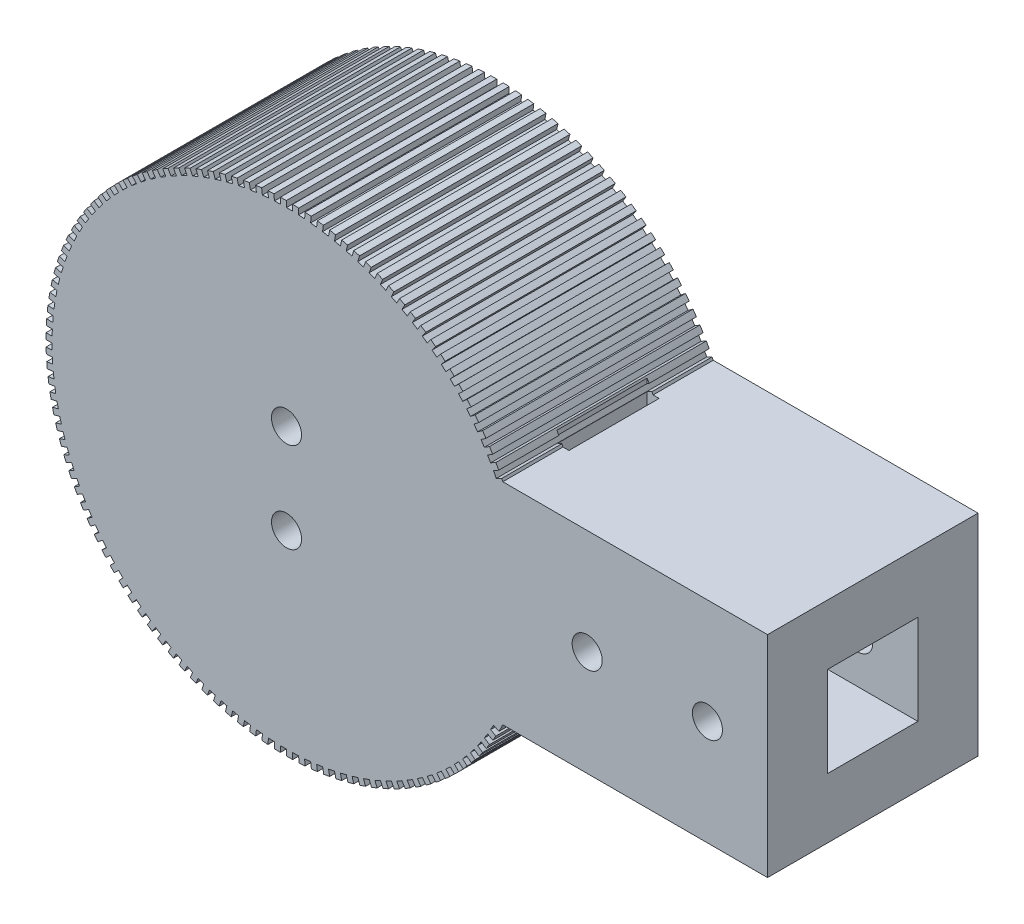
from build123d import *

# Parameters (mm, degrees)
SKETCH1_R               = 40
BOSS_EXTRUDE1_DEPTH     = 35
SKETCH2_W               = 35
SKETCH2_H               = 35
BOSS_EXTRUDE2_DEPTH     = 80
SKETCH3_R               = 2.5
CUT_EXTRUDE1_DEPTH      = 1
CUT_EXTRUDE1_DEPTH_BACK = 36
SKETCH4_W               = 2
SKETCH4_H               = 15
CUT_EXTRUDE2_DEPTH      = 23.5
CUT_EXTRUDE2_DEPTH_BACK = 58.5
SKETCH6_W               = 15
SKETCH6_H               = 15
CUT_EXTRUDE4_DEPTH      = 47.5
SKETCH7_R               = 2.5
CUT_EXTRUDE5_DEPTH      = 1
CUT_EXTRUDE5_DEPTH_BACK = 36
CUT_EXTRUDE9_DEPTH      = 36


with BuildPart() as part:
    # Sketch1 → Boss-Extrude1 (new body)
    with BuildSketch(Plane.XY):
        Circle(SKETCH1_R)
    extrude(amount=BOSS_EXTRUDE1_DEPTH)

    # Sketch2 → Boss-Extrude2 (add)
    with BuildSketch(Plane(origin=(0, 0, 0), x_dir=(0, 0, -1), z_dir=(1, 0, 0))):
        with Locations((-17.5, 0)):
            Rectangle(SKETCH2_W, SKETCH2_H)
    extrude(amount=BOSS_EXTRUDE2_DEPTH)

    # Sketch3 → Cut-Extrude1 (cut, two sides)
    with BuildSketch(Plane(origin=(0, 0, 0), x_dir=(-1, 0, 0), z_dir=(0, 0, -1))) as cut_extrude1_sk:
        with Locations((0, 7.5)):
            Circle(SKETCH3_R)
        with Locations((0, -7.5)):
            Circle(SKETCH3_R)
    extrude(amount=CUT_EXTRUDE1_DEPTH, mode=Mode.SUBTRACT)
    extrude(cut_extrude1_sk.sketch, amount=-CUT_EXTRUDE1_DEPTH_BACK, mode=Mode.SUBTRACT)

    # Sketch4 → Cut-Extrude2 (cut, two sides)
    with BuildSketch(Plane(origin=(0, 17.5, 0), x_dir=(1, 0, 0), z_dir=(0, 1, 0))) as cut_extrude2_sk:
        with Locations((35.968736425, -17.5)):
            Rectangle(SKETCH4_W, SKETCH4_H)
    extrude(amount=CUT_EXTRUDE2_DEPTH, mode=Mode.SUBTRACT)
    extrude(cut_extrude2_sk.sketch, amount=-CUT_EXTRUDE2_DEPTH_BACK, mode=Mode.SUBTRACT)

    # Sketch6 → Cut-Extrude4 (cut)
    with BuildSketch(Plane(origin=(80, 0, 0), x_dir=(0, 0, -1), z_dir=(1, 0, 0))):
        with Locations((-17.5, 0)):
            Rectangle(SKETCH6_W, SKETCH6_H)
    extrude(amount=-CUT_EXTRUDE4_DEPTH, mode=Mode.SUBTRACT)

    # Sketch7 → Cut-Extrude5 (cut, two sides)
    with BuildSketch(Plane.XY.offset(35)) as cut_extrude5_sk:
        with Locations((50, 0)):
            Circle(SKETCH7_R)
        with Locations((70, 0)):
            Circle(SKETCH7_R)
    extrude(amount=CUT_EXTRUDE5_DEPTH, mode=Mode.SUBTRACT)
    extrude(cut_extrude5_sk.sketch, amount=-CUT_EXTRUDE5_DEPTH_BACK, mode=Mode.SUBTRACT)

    # Sketch8 → Cut-Extrude9 (cut, through all)
    with BuildSketch(Plane.XY.offset(35)):
        with BuildLine():
            Line((-39, 0), (-40.006638535, 0))
            Line((-40.006638535, 0), (-39.994138656, 1))
            Line((-39.994138656, 1), (-38.987177379, 1))
            Line((-38.987177379, 1), (-38.948289506, 2.007671436))
            Line((-38.948289506, 2.007671436), (-39.953593328, 2.059491934))
            Line((-39.953593328, 2.059491934), (-39.889631269, 3.057522546))
            Line((-39.889631269, 3.057522546), (-38.884005132, 3.005685433))
            Line((-38.884005132, 3.005685433), (-38.793295149, 4.010018888))
            Line((-38.793295149, 4.010018888), (-39.794598375, 4.113522466))
            Line((-39.794598375, 4.113522466), (-39.67934375, 5.106937092))
            Line((-39.67934375, 5.106937092), (-38.677719493, 5.003400329))
            Line((-38.677719493, 5.003400329), (-38.535427948, 6.001732491))
            Line((-38.535427948, 6.001732491), (-39.5300753, 6.156644676))
            Line((-39.5300753, 6.156644676), (-39.363833744, 7.142808959))
            Line((-39.363833744, 7.142808959), (-38.368867494, 6.987847107))
            Line((-38.368867494, 6.987847107), (-38.175371719, 7.977530579))
            Line((-38.175371719, 7.977530579), (-39.160725572, 8.183440571))
            Line((-39.160725572, 8.183440571), (-38.943937928, 9.15973938))
            Line((-38.943937928, 9.15973938), (-37.958268157, 8.95376337))
            Line((-37.958268157, 8.95376337), (-37.714081267, 9.932173689))
            Line((-37.714081267, 9.932173689), (-38.687528639, 10.188535453))
            Line((-38.687528639, 10.188535453), (-38.42076979, 11.15237982))
            Line((-38.42076979, 11.15237982), (-37.447010317, 10.895935863))
            Line((-37.447010317, 10.895935863), (-37.152779851, 11.860478461))
            Line((-37.152779851, 11.860478461), (-38.111739335, 12.16661217))
            Line((-38.111739335, 12.16661217), (-37.795716677, 13.115446152))
            Line((-37.795716677, 13.115446152), (-36.836449737, 12.809214292))
            Line((-36.836449737, 12.809214292), (-36.492955943, 13.757331375))
            Line((-36.492955943, 13.757331375), (-37.434884551, 14.112425219))
            Line((-37.434884551, 14.112425219), (-37.070436117, 15.04373268))
            Line((-37.070436117, 15.04373268), (-36.128205514, 14.688524988))
            Line((-36.128205514, 14.688524988), (-35.736359275, 15.61770232))
            Line((-35.736359275, 15.61770232), (-36.658759181, 16.020814653))
            Line((-36.658759181, 16.020814653), (-36.246851426, 16.932125933))
            Line((-36.246851426, 16.932125933), (-35.324155785, 16.528884356))
            Line((-35.324155785, 16.528884356), (-34.884996207, 17.436657926))
            Line((-34.884996207, 17.436657926), (-35.785421373, 17.886719767))
            Line((-35.785421373, 17.886719767), (-35.3271466, 18.775618231))
            Line((-35.3271466, 18.775618231), (-34.426432745, 18.325412094))
            Line((-34.426432745, 18.325412094), (-33.9411244, 19.20937465))
            Line((-33.9411244, 19.20937465), (-34.81718706, 19.705192516))
            Line((-34.81718706, 19.705192516), (-34.313760532, 20.569320966))
            Line((-34.313760532, 20.569320966), (-33.437416995, 20.073344134))
            Line((-33.437416995, 20.073344134), (-32.907246833, 20.931151566))
            Line((-32.907246833, 20.931151566), (-33.756623827, 21.471410636))
            Line((-33.756623827, 21.471410636), (-33.209380541, 22.308477559))
            Line((-33.209380541, 22.308477559), (-32.359731225, 21.768045274))
            Line((-32.359731225, 21.768045274), (-31.786105163, 22.59742283))
            Line((-31.786105163, 22.59742283), (-32.606544095, 23.180690435))
            Line((-32.606544095, 23.180690435), (-32.016935241, 23.98847608))
            Line((-32.016935241, 23.98847608), (-31.196233266, 23.40502147))
            Line((-31.196233266, 23.40502147), (-30.580672456, 24.203769791))
            Line((-30.580672456, 24.203769791), (-31.36999767, 24.828499211))
            Line((-31.36999767, 24.828499211), (-30.739586786, 25.604861474))
            Line((-30.739586786, 25.604861474), (-29.950008504, 24.979931758))
            Line((-29.950008504, 24.979931758), (-29.294145304, 25.745932706))
            Line((-29.294145304, 25.745932706), (-30.05026365, 26.41046727))
            Line((-30.05026365, 26.41046727), (-29.380722472, 27.153347379))
            Line((-29.380722472, 27.153347379), (-28.624361703, 26.488599757))
            Line((-28.624361703, 26.488599757), (-27.929935344, 27.219822036))
            Line((-27.929935344, 27.219822036), (-28.650841734, 27.922399517))
            Line((-28.650841734, 27.922399517), (-27.943945764, 28.629827489))
            Line((-27.943945764, 28.629827489), (-27.222808242, 27.927024751))
            Line((-27.222808242, 27.927024751), (-26.491660217, 28.621529291))
            Line((-26.491660217, 28.621529291), (-27.175442936, 29.360286581))
            Line((-27.175442936, 29.360286581), (-26.433066735, 30.030386442))
            Line((-26.433066735, 30.030386442), (-25.749064786, 29.291392296))
            Line((-25.749064786, 29.291392296), (-24.983133969, 29.947337395))
            Line((-24.983133969, 29.947337395), (-25.627979748, 30.720315443))
            Line((-25.627979748, 30.720315443), (-24.852091965, 31.351310209))
            Line((-24.852091965, 31.351310209), (-24.20703944, 30.578084334))
            Line((-24.20703944, 30.578084334), (-23.408356941, 31.193730545))
            Line((-23.408356941, 31.193730545), (-24.012555765, 31.99887955))
            Line((-24.012555765, 31.99887955), (-23.205213915, 32.589095938))
            Line((-23.205213915, 32.589095938), (-22.600821377, 31.78368879))
            Line((-22.600821377, 31.78368879), (-21.771505159, 32.357403529))
            Line((-21.771505159, 32.357403529), (-22.333454802, 33.192588382))
            Line((-22.333454802, 33.192588382), (-21.496799809, 33.740461242))
            Line((-21.496799809, 33.740461242), (-20.934669998, 32.905008617))
            Line((-20.934669998, 32.905008617), (-20.076919259, 33.435270495))
            Line((-20.076919259, 33.435270495), (-20.59512953, 34.298276436))
            Line((-20.59512953, 34.298276436), (-19.731380055, 34.802352909))
            Line((-19.731380055, 34.802352909), (-19.213003638, 33.939070276))
            Line((-19.213003638, 33.939070276), (-18.329092978, 34.424473135))
            Line((-18.329092978, 34.424473135), (-18.802189678, 35.313011627))
            Line((-18.802189678, 35.313011627), (-17.913636228, 35.771954992))
            Line((-17.913636228, 35.771954992), (-17.440387846, 34.883131622))
            Line((-17.440387846, 34.883131622), (-16.532661238, 35.32238826))
            Line((-16.532661238, 35.32238826), (-16.959389799, 36.234103059))
            Line((-16.959389799, 36.234103059), (-16.048388657, 36.646696282))
            Line((-16.048388657, 36.646696282), (-15.621523281, 35.734689174))
            Line((-15.621523281, 35.734689174), (-14.692387852, 36.126634762))
            Line((-14.692387852, 36.126634762), (-15.071616667, 37.059108164))
            Line((-15.071616667, 37.059108164), (-14.140583646, 37.424257121))
            Line((-14.140583646, 37.424257121), (-13.761233245, 36.491484754))
            Line((-13.761233245, 36.491484754), (-12.813152895, 36.835079923))
            Line((-12.813152895, 36.835079923), (-13.143876317, 37.785839176))
            Line((-13.143876317, 37.785839176), (-12.195280348, 38.102575557))
            Line((-12.195280348, 38.102575557), (-11.864450891, 37.151511477))
            Line((-11.864450891, 37.151511477), (-10.899939759, 37.445845073))
            Line((-10.899939759, 37.445845073), (-11.181280769, 38.412368935))
            Line((-11.181280769, 38.412368935), (-10.217637359, 38.679852813))
            Line((-10.217637359, 38.679852813), (-9.936206147, 37.71301907))
            Line((-9.936206147, 37.71301907), (-8.957821943, 37.957310574))
            Line((-8.957821943, 37.957310574), (-9.189034475, 38.937035998))
            Line((-9.189034475, 38.937035998), (-8.212899033, 39.154558053))
            Line((-8.212899033, 39.154558053), (-7.981612371, 38.174518516))
            Line((-7.981612371, 38.174518516), (-6.991949594, 38.368120111))
            Line((-6.991949594, 38.368120111), (-7.172420514, 39.35844904))
            Line((-7.172420514, 39.35844904), (-6.186381575, 39.525432444))
            Line((-6.186381575, 39.525432444), (-6.005852793, 38.534786002))
            Line((-6.005852793, 38.534786002), (-5.007535851, 38.677184291))
            Line((-5.007535851, 38.677184291), (-5.136786583, 39.675490551))
            Line((-5.136786583, 39.675490551), (-4.143458945, 39.791492493))
            Line((-4.143458945, 39.791492493), (-4.014166773, 38.792866163))
            Line((-4.014166773, 38.792866163), (-3.009843023, 38.883683531))
            Line((-3.009843023, 38.883683531), (-3.087530817, 39.887319794))
            Line((-3.087530817, 39.887319794), (-2.089548607, 39.952032658))
            Line((-2.089548607, 39.952032658), (-2.011835905, 38.948074616))
            Line((-2.011835905, 38.948074616), (-1.004168633, 38.987070233))
            Line((-1.004168633, 38.987070233), (-1.030087475, 39.993375035))
            Line((-1.030087475, 39.993375035), (-0.030097161, 40.006627214))
            Line((-0.030097161, 40.006627214), (-0.004170009, 38.999999777))
            Line((-0.004170009, 38.999999777), (1.004168633, 38.987070233))
            Line((1.004168633, 38.987070233), (1.030087475, 39.993375035))
            Line((1.030087475, 39.993375035), (2.029434096, 39.955131387))
            Line((2.029434096, 39.955131387), (2.003506944, 38.94850395))
            Line((2.003506944, 38.94850395), (3.009843023, 38.883683531))
            Line((3.009843023, 38.883683531), (3.087530817, 39.887319794))
            Line((3.087530817, 39.887319794), (4.08358366, 39.797681734))
            Line((4.08358366, 39.797681734), (4.005870958, 38.793723692))
            Line((4.005870958, 38.793723692), (5.007535851, 38.677184291))
            Line((5.007535851, 38.677184291), (5.136786583, 39.675490551))
            Line((5.136786583, 39.675490551), (6.126904293, 39.534695783))
            Line((6.126904293, 39.534695783), (5.997612121, 38.536069452))
            Line((5.997612121, 38.536069452), (6.991949594, 38.368120111))
            Line((6.991949594, 38.368120111), (7.172420514, 39.35844904))
            Line((7.172420514, 39.35844904), (8.153977478, 39.166870926))
            Line((8.153977478, 39.166870926), (7.973448696, 38.176224485))
            Line((7.973448696, 38.176224485), (8.957821943, 37.957310574))
            Line((8.957821943, 37.957310574), (9.189034475, 38.937035998))
            Line((9.189034475, 38.937035998), (10.15942778, 38.695182569))
            Line((10.15942778, 38.695182569), (9.928141118, 37.715143032))
            Line((9.928141118, 37.715143032), (10.899939759, 37.445845073))
            Line((10.899939759, 37.445845073), (11.181280769, 38.412368935))
            Line((11.181280769, 38.412368935), (12.137937106, 38.120881544))
            Line((12.137937106, 38.120881544), (11.856505895, 37.154047801))
            Line((11.856505895, 37.154047801), (12.813152895, 36.835079923))
            Line((12.813152895, 36.835079923), (13.143876317, 37.785839176))
            Line((13.143876317, 37.785839176), (14.084258805, 37.445490794))
            Line((14.084258805, 37.445490794), (13.753429349, 36.494426713))
            Line((13.753429349, 36.494426713), (14.692387852, 36.126634762))
            Line((14.692387852, 36.126634762), (15.071616667, 37.059108164))
            Line((15.071616667, 37.059108164), (15.993231582, 36.670801333))
            Line((15.993231582, 36.670801333), (15.613881181, 35.738028967))
            Line((15.613881181, 35.738028967), (16.532661238, 35.32238826))
            Line((16.532661238, 35.32238826), (16.959389799, 36.234103059))
            Line((16.959389799, 36.234103059), (17.859793184, 35.7988675))
            Line((17.859793184, 35.7988675), (17.432927807, 34.886860393))
            Line((17.432927807, 34.886860393), (18.329092978, 34.424473135))
            Line((18.329092978, 34.424473135), (18.802189678, 35.313011627))
            Line((18.802189678, 35.313011627), (19.678993824, 34.832001506))
            Line((19.678993824, 34.832001506), (19.205745443, 33.943178136))
            Line((19.205745443, 33.943178136), (20.076919259, 33.435270495))
            Line((20.076919259, 33.435270495), (20.59512953, 34.298276436))
            Line((20.59512953, 34.298276436), (21.446009311, 33.772767306))
            Line((21.446009311, 33.772767306), (20.927632894, 32.909484673))
            Line((20.927632894, 32.909484673), (21.771505159, 32.357403529))
            Line((21.771505159, 32.357403529), (22.333454802, 33.192588382))
            Line((22.333454802, 33.192588382), (23.156153836, 32.623973798))
            Line((23.156153836, 32.623973798), (22.594024025, 31.788521173))
            Line((22.594024025, 31.788521173), (23.408356941, 31.193730545))
            Line((23.408356941, 31.193730545), (24.012555765, 31.99887955))
            Line((24.012555765, 31.99887955), (24.804892405, 31.388667376))
            Line((24.804892405, 31.388667376), (24.200499866, 30.583260229))
            Line((24.200499866, 30.583260229), (24.983133969, 29.947337395))
            Line((24.983133969, 29.947337395), (25.627979748, 30.720315443))
            Line((25.627979748, 30.720315443), (26.387852857, 30.070123852))
            Line((26.387852857, 30.070123852), (25.742800332, 29.296897977))
            Line((25.742800332, 29.296897977), (26.491660217, 28.621529291))
            Line((26.491660217, 28.621529291), (27.175442936, 29.360286581))
            Line((27.175442936, 29.360286581), (27.900837468, 28.671839764))
            Line((27.900837468, 28.671839764), (27.216835519, 27.932845618))
            Line((27.216835519, 27.932845618), (27.929935344, 27.219822036))
            Line((27.929935344, 27.219822036), (28.650841734, 27.922399517))
            Line((28.650841734, 27.922399517), (29.339834073, 27.197523112))
            Line((29.339834073, 27.197523112), (28.618696551, 26.494720374))
            Line((28.618696551, 26.494720374), (29.294145304, 25.745932706))
            Line((29.294145304, 25.745932706), (30.05026365, 26.41046727))
            Line((30.05026365, 26.41046727), (30.701026713, 25.651083518))
            Line((30.701026713, 25.651083518), (29.944665945, 24.986335895))
            Line((29.944665945, 24.986335895), (30.580672456, 24.203769791))
            Line((30.580672456, 24.203769791), (31.36999767, 24.828499211))
            Line((31.36999767, 24.828499211), (31.980805749, 24.036621861))
            Line((31.980805749, 24.036621861), (31.191227467, 23.411692145))
            Line((31.191227467, 23.411692145), (31.786105163, 22.59742283))
            Line((31.786105163, 22.59742283), (32.606544095, 23.180690435))
            Line((32.606544095, 23.180690435), (33.175777438, 22.358419405))
            Line((33.175777438, 22.358419405), (32.355075462, 21.774964795))
            Line((32.355075462, 21.774964795), (32.907246833, 20.931151566))
            Line((32.907246833, 20.931151566), (33.756623827, 21.471410636))
            Line((33.756623827, 21.471410636), (34.282772929, 20.620926439))
            Line((34.282772929, 20.620926439), (33.433123613, 20.080494154))
            Line((33.433123613, 20.080494154), (33.9411244, 19.20937465))
            Line((33.9411244, 19.20937465), (34.81718706, 19.705192516))
            Line((34.81718706, 19.705192516), (35.298856668, 18.828750484))
            Line((35.298856668, 18.828750484), (34.422513131, 18.332773652))
            Line((34.422513131, 18.332773652), (34.884996207, 17.436657926))
            Line((34.884996207, 17.436657926), (35.785421373, 17.886719767))
            Line((35.785421373, 17.886719767), (45.709703325, 22.847199297))
            ThreePointArc((45.709703325, 22.847199297), (-51.10158015, 0), (45.709703325, -22.847199297))
            Line((45.709703325, -22.847199297), (35.785421373, -17.886719767))
            Line((35.785421373, -17.886719767), (35.3271466, -18.775618231))
            Line((35.3271466, -18.775618231), (34.426432745, -18.325412094))
            Line((34.426432745, -18.325412094), (33.9411244, -19.20937465))
            Line((33.9411244, -19.20937465), (34.81718706, -19.705192516))
            Line((34.81718706, -19.705192516), (34.313760532, -20.569320966))
            Line((34.313760532, -20.569320966), (33.437416995, -20.073344134))
            Line((33.437416995, -20.073344134), (32.907246833, -20.931151566))
            Line((32.907246833, -20.931151566), (33.756623827, -21.471410636))
            Line((33.756623827, -21.471410636), (33.209380541, -22.308477559))
            Line((33.209380541, -22.308477559), (32.359731225, -21.768045274))
            Line((32.359731225, -21.768045274), (31.786105163, -22.59742283))
            Line((31.786105163, -22.59742283), (32.606544095, -23.180690435))
            Line((32.606544095, -23.180690435), (32.016935241, -23.98847608))
            Line((32.016935241, -23.98847608), (31.196233266, -23.40502147))
            Line((31.196233266, -23.40502147), (30.580672456, -24.203769791))
            Line((30.580672456, -24.203769791), (31.36999767, -24.828499211))
            Line((31.36999767, -24.828499211), (30.739586786, -25.604861474))
            Line((30.739586786, -25.604861474), (29.950008504, -24.979931758))
            Line((29.950008504, -24.979931758), (29.294145304, -25.745932706))
            Line((29.294145304, -25.745932706), (30.05026365, -26.41046727))
            Line((30.05026365, -26.41046727), (29.380722472, -27.153347379))
            Line((29.380722472, -27.153347379), (28.624361703, -26.488599757))
            Line((28.624361703, -26.488599757), (27.929935344, -27.219822036))
            Line((27.929935344, -27.219822036), (28.650841734, -27.922399517))
            Line((28.650841734, -27.922399517), (27.943945764, -28.629827489))
            Line((27.943945764, -28.629827489), (27.222808242, -27.927024751))
            Line((27.222808242, -27.927024751), (26.491660217, -28.621529291))
            Line((26.491660217, -28.621529291), (27.175442936, -29.360286581))
            Line((27.175442936, -29.360286581), (26.433066735, -30.030386442))
            Line((26.433066735, -30.030386442), (25.749064786, -29.291392296))
            Line((25.749064786, -29.291392296), (24.983133969, -29.947337395))
            Line((24.983133969, -29.947337395), (25.627979748, -30.720315443))
            Line((25.627979748, -30.720315443), (24.852091965, -31.351310209))
            Line((24.852091965, -31.351310209), (24.20703944, -30.578084334))
            Line((24.20703944, -30.578084334), (23.408356941, -31.193730545))
            Line((23.408356941, -31.193730545), (24.012555765, -31.99887955))
            Line((24.012555765, -31.99887955), (23.205213915, -32.589095938))
            Line((23.205213915, -32.589095938), (22.600821377, -31.78368879))
            Line((22.600821377, -31.78368879), (21.771505159, -32.357403529))
            Line((21.771505159, -32.357403529), (22.333454802, -33.192588382))
            Line((22.333454802, -33.192588382), (21.496799809, -33.740461242))
            Line((21.496799809, -33.740461242), (20.934669998, -32.905008617))
            Line((20.934669998, -32.905008617), (20.076919259, -33.435270495))
            Line((20.076919259, -33.435270495), (20.59512953, -34.298276436))
            Line((20.59512953, -34.298276436), (19.731380055, -34.802352909))
            Line((19.731380055, -34.802352909), (19.213003638, -33.939070276))
            Line((19.213003638, -33.939070276), (18.329092978, -34.424473135))
            Line((18.329092978, -34.424473135), (18.802189678, -35.313011627))
            Line((18.802189678, -35.313011627), (17.913636228, -35.771954992))
            Line((17.913636228, -35.771954992), (17.440387846, -34.883131622))
            Line((17.440387846, -34.883131622), (16.532661238, -35.32238826))
            Line((16.532661238, -35.32238826), (16.959389799, -36.234103059))
            Line((16.959389799, -36.234103059), (16.048388657, -36.646696282))
            Line((16.048388657, -36.646696282), (15.621523281, -35.734689174))
            Line((15.621523281, -35.734689174), (14.692387852, -36.126634762))
            Line((14.692387852, -36.126634762), (15.071616667, -37.059108164))
            Line((15.071616667, -37.059108164), (14.140583646, -37.424257121))
            Line((14.140583646, -37.424257121), (13.761233245, -36.491484754))
            Line((13.761233245, -36.491484754), (12.813152895, -36.835079923))
            Line((12.813152895, -36.835079923), (13.143876317, -37.785839176))
            Line((13.143876317, -37.785839176), (12.195280348, -38.102575557))
            Line((12.195280348, -38.102575557), (11.864450891, -37.151511477))
            Line((11.864450891, -37.151511477), (10.899939759, -37.445845073))
            Line((10.899939759, -37.445845073), (11.181280769, -38.412368935))
            Line((11.181280769, -38.412368935), (10.217637359, -38.679852813))
            Line((10.217637359, -38.679852813), (9.936206147, -37.71301907))
            Line((9.936206147, -37.71301907), (8.957821943, -37.957310574))
            Line((8.957821943, -37.957310574), (9.189034475, -38.937035998))
            Line((9.189034475, -38.937035998), (8.212899033, -39.154558053))
            Line((8.212899033, -39.154558053), (7.981612371, -38.174518516))
            Line((7.981612371, -38.174518516), (6.991949594, -38.368120111))
            Line((6.991949594, -38.368120111), (7.172420514, -39.35844904))
            Line((7.172420514, -39.35844904), (6.186381575, -39.525432444))
            Line((6.186381575, -39.525432444), (6.005852793, -38.534786002))
            Line((6.005852793, -38.534786002), (5.007535851, -38.677184291))
            Line((5.007535851, -38.677184291), (5.136786583, -39.675490551))
            Line((5.136786583, -39.675490551), (4.143458945, -39.791492493))
            Line((4.143458945, -39.791492493), (4.014166773, -38.792866163))
            Line((4.014166773, -38.792866163), (3.009843023, -38.883683531))
            Line((3.009843023, -38.883683531), (3.087530817, -39.887319794))
            Line((3.087530817, -39.887319794), (2.089548607, -39.952032658))
            Line((2.089548607, -39.952032658), (2.011835905, -38.948074616))
            Line((2.011835905, -38.948074616), (1.004168633, -38.987070233))
            Line((1.004168633, -38.987070233), (1.030087475, -39.993375035))
            Line((1.030087475, -39.993375035), (0.030097161, -40.006627214))
            Line((0.030097161, -40.006627214), (0.004170009, -38.999999777))
            Line((0.004170009, -38.999999777), (-1.004168633, -38.987070233))
            Line((-1.004168633, -38.987070233), (-1.030087475, -39.993375035))
            Line((-1.030087475, -39.993375035), (-2.029434096, -39.955131387))
            Line((-2.029434096, -39.955131387), (-2.003506944, -38.94850395))
            Line((-2.003506944, -38.94850395), (-3.009843023, -38.883683531))
            Line((-3.009843023, -38.883683531), (-3.087530817, -39.887319794))
            Line((-3.087530817, -39.887319794), (-4.08358366, -39.797681734))
            Line((-4.08358366, -39.797681734), (-4.005870958, -38.793723692))
            Line((-4.005870958, -38.793723692), (-5.007535851, -38.677184291))
            Line((-5.007535851, -38.677184291), (-5.136786583, -39.675490551))
            Line((-5.136786583, -39.675490551), (-6.126904293, -39.534695783))
            Line((-6.126904293, -39.534695783), (-5.997612121, -38.536069452))
            Line((-5.997612121, -38.536069452), (-6.991949594, -38.368120111))
            Line((-6.991949594, -38.368120111), (-7.172420514, -39.35844904))
            Line((-7.172420514, -39.35844904), (-8.153977478, -39.166870926))
            Line((-8.153977478, -39.166870926), (-7.973448696, -38.176224485))
            Line((-7.973448696, -38.176224485), (-8.957821943, -37.957310574))
            Line((-8.957821943, -37.957310574), (-9.189034475, -38.937035998))
            Line((-9.189034475, -38.937035998), (-10.15942778, -38.695182569))
            Line((-10.15942778, -38.695182569), (-9.928141118, -37.715143032))
            Line((-9.928141118, -37.715143032), (-10.899939759, -37.445845073))
            Line((-10.899939759, -37.445845073), (-11.181280769, -38.412368935))
            Line((-11.181280769, -38.412368935), (-12.137937106, -38.120881544))
            Line((-12.137937106, -38.120881544), (-11.856505895, -37.154047801))
            Line((-11.856505895, -37.154047801), (-12.813152895, -36.835079923))
            Line((-12.813152895, -36.835079923), (-13.143876317, -37.785839176))
            Line((-13.143876317, -37.785839176), (-14.084258805, -37.445490794))
            Line((-14.084258805, -37.445490794), (-13.753429349, -36.494426713))
            Line((-13.753429349, -36.494426713), (-14.692387852, -36.126634762))
            Line((-14.692387852, -36.126634762), (-15.071616667, -37.059108164))
            Line((-15.071616667, -37.059108164), (-15.993231582, -36.670801333))
            Line((-15.993231582, -36.670801333), (-15.613881181, -35.738028967))
            Line((-15.613881181, -35.738028967), (-16.532661238, -35.32238826))
            Line((-16.532661238, -35.32238826), (-16.959389799, -36.234103059))
            Line((-16.959389799, -36.234103059), (-17.859793184, -35.7988675))
            Line((-17.859793184, -35.7988675), (-17.432927807, -34.886860393))
            Line((-17.432927807, -34.886860393), (-18.329092978, -34.424473135))
            Line((-18.329092978, -34.424473135), (-18.802189678, -35.313011627))
            Line((-18.802189678, -35.313011627), (-19.678993824, -34.832001506))
            Line((-19.678993824, -34.832001506), (-19.205745443, -33.943178136))
            Line((-19.205745443, -33.943178136), (-20.076919259, -33.435270495))
            Line((-20.076919259, -33.435270495), (-20.59512953, -34.298276436))
            Line((-20.59512953, -34.298276436), (-21.446009311, -33.772767306))
            Line((-21.446009311, -33.772767306), (-20.927632894, -32.909484673))
            Line((-20.927632894, -32.909484673), (-21.771505159, -32.357403529))
            Line((-21.771505159, -32.357403529), (-22.333454802, -33.192588382))
            Line((-22.333454802, -33.192588382), (-23.156153836, -32.623973798))
            Line((-23.156153836, -32.623973798), (-22.594024025, -31.788521173))
            Line((-22.594024025, -31.788521173), (-23.408356941, -31.193730545))
            Line((-23.408356941, -31.193730545), (-24.012555765, -31.99887955))
            Line((-24.012555765, -31.99887955), (-24.804892405, -31.388667376))
            Line((-24.804892405, -31.388667376), (-24.200499866, -30.583260229))
            Line((-24.200499866, -30.583260229), (-24.983133969, -29.947337395))
            Line((-24.983133969, -29.947337395), (-25.627979748, -30.720315443))
            Line((-25.627979748, -30.720315443), (-26.387852857, -30.070123852))
            Line((-26.387852857, -30.070123852), (-25.742800332, -29.296897977))
            Line((-25.742800332, -29.296897977), (-26.491660217, -28.621529291))
            Line((-26.491660217, -28.621529291), (-27.175442936, -29.360286581))
            Line((-27.175442936, -29.360286581), (-27.900837468, -28.671839764))
            Line((-27.900837468, -28.671839764), (-27.216835519, -27.932845618))
            Line((-27.216835519, -27.932845618), (-27.929935344, -27.219822036))
            Line((-27.929935344, -27.219822036), (-28.650841734, -27.922399517))
            Line((-28.650841734, -27.922399517), (-29.339834073, -27.197523112))
            Line((-29.339834073, -27.197523112), (-28.618696551, -26.494720374))
            Line((-28.618696551, -26.494720374), (-29.294145304, -25.745932706))
            Line((-29.294145304, -25.745932706), (-30.05026365, -26.41046727))
            Line((-30.05026365, -26.41046727), (-30.701026713, -25.651083518))
            Line((-30.701026713, -25.651083518), (-29.944665945, -24.986335895))
            Line((-29.944665945, -24.986335895), (-30.580672456, -24.203769791))
            Line((-30.580672456, -24.203769791), (-31.36999767, -24.828499211))
            Line((-31.36999767, -24.828499211), (-31.980805749, -24.036621861))
            Line((-31.980805749, -24.036621861), (-31.191227467, -23.411692145))
            Line((-31.191227467, -23.411692145), (-31.786105163, -22.59742283))
            Line((-31.786105163, -22.59742283), (-32.606544095, -23.180690435))
            Line((-32.606544095, -23.180690435), (-33.175777438, -22.358419405))
            Line((-33.175777438, -22.358419405), (-32.355075462, -21.774964795))
            Line((-32.355075462, -21.774964795), (-32.907246833, -20.931151566))
            Line((-32.907246833, -20.931151566), (-33.756623827, -21.471410636))
            Line((-33.756623827, -21.471410636), (-34.282772929, -20.620926439))
            Line((-34.282772929, -20.620926439), (-33.433123613, -20.080494154))
            Line((-33.433123613, -20.080494154), (-33.9411244, -19.20937465))
            Line((-33.9411244, -19.20937465), (-34.81718706, -19.705192516))
            Line((-34.81718706, -19.705192516), (-35.298856668, -18.828750484))
            Line((-35.298856668, -18.828750484), (-34.422513131, -18.332773652))
            Line((-34.422513131, -18.332773652), (-34.884996207, -17.436657926))
            Line((-34.884996207, -17.436657926), (-35.785421373, -17.886719767))
            Line((-35.785421373, -17.886719767), (-36.221334186, -16.986644067))
            Line((-36.221334186, -16.986644067), (-35.320620331, -16.53643793))
            Line((-35.320620331, -16.53643793), (-35.736359275, -15.61770232))
            Line((-35.736359275, -15.61770232), (-36.658759181, -16.020814653))
            Line((-36.658759181, -16.020814653), (-37.047759237, -15.099492124))
            Line((-37.047759237, -15.099492124), (-36.125063596, -14.696250547))
            Line((-36.125063596, -14.696250547), (-36.492955943, -13.757331375))
            Line((-36.492955943, -13.757331375), (-37.434884551, -14.112425219))
            Line((-37.434884551, -14.112425219), (-37.77594029, -13.172299042))
            Line((-37.77594029, -13.172299042), (-36.833709687, -12.81709135))
            Line((-36.833709687, -12.81709135), (-37.152779851, -11.860478461))
            Line((-37.152779851, -11.860478461), (-38.111739335, -12.16661217))
            Line((-38.111739335, -12.16661217), (-38.403946341, -11.210175391))
            Line((-38.403946341, -11.210175391), (-37.444679401, -10.903943531))
            Line((-37.444679401, -10.903943531), (-37.714081267, -9.932173689))
            Line((-37.714081267, -9.932173689), (-38.687528639, -10.188535453))
            Line((-38.687528639, -10.188535453), (-38.93011203, -9.21832437))
            Line((-38.93011203, -9.21832437), (-37.956352557, -8.961880413))
            Line((-37.956352557, -8.961880413), (-38.175371719, -7.977530579))
            Line((-38.175371719, -7.977530579), (-39.160725572, -8.183440571))
            Line((-39.160725572, -8.183440571), (-39.353042061, -7.20202801))
            Line((-39.353042061, -7.20202801), (-38.36737229, -6.996052))
            Line((-38.36737229, -6.996052), (-38.535427948, -6.001732491))
            Line((-38.535427948, -6.001732491), (-39.5300753, -6.156644676))
            Line((-39.5300753, -6.156644676), (-39.671614898, -5.166633167))
            Line((-39.671614898, -5.166633167), (-38.676648648, -5.011671315))
            Line((-38.676648648, -5.011671315), (-38.793295149, -4.010018888))
            Line((-38.793295149, -4.010018888), (-39.794598375, -4.113522466))
            Line((-39.794598375, -4.113522466), (-39.884985744, -3.117537341))
            Line((-39.884985744, -3.117537341), (-38.883361487, -3.014000578))
            Line((-38.883361487, -3.014000578), (-38.948289506, -2.007671436))
            Line((-38.948289506, -2.007671436), (-39.953593328, -2.059491934))
            Line((-39.953593328, -2.059491934), (-39.992588778, -1.060174366))
            Line((-39.992588778, -1.060174366), (-38.986962641, -1.008337254))
            Line((-38.986962641, -1.008337254), (-39, 0))
        make_face()
    extrude(amount=-CUT_EXTRUDE9_DEPTH, mode=Mode.SUBTRACT)


solid = part.part
